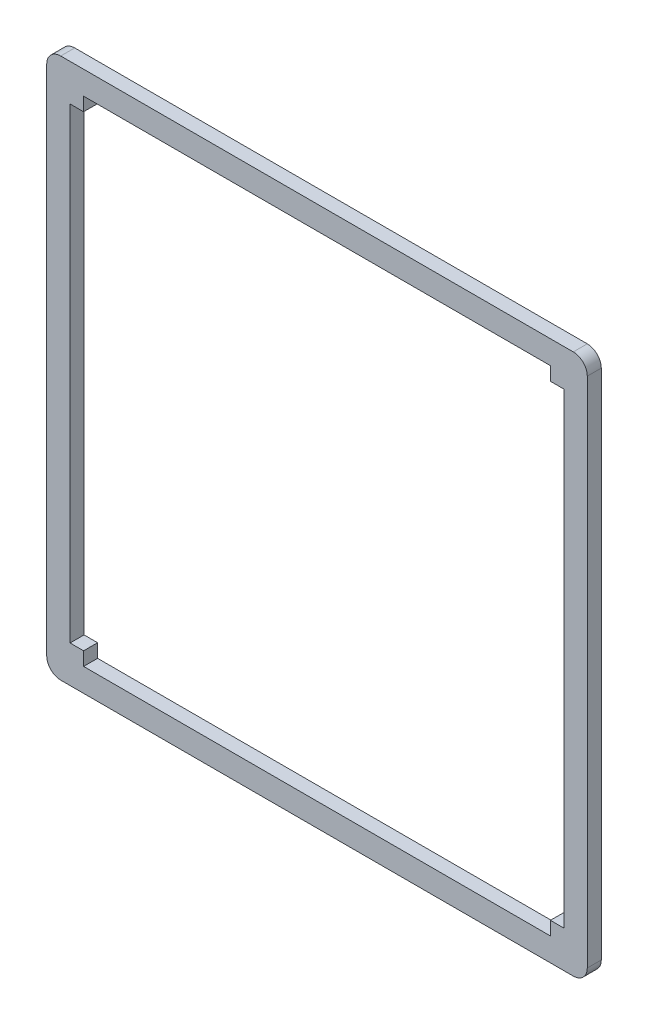
from build123d import *

# Parameters (mm, degrees)
EXTRUDE_1_DEPTH = 3


with BuildPart() as part:
    # 草图1 → 凸台-拉伸1 (new body)
    with BuildSketch(Plane.XY):
        with BuildLine():
            Line((-4.9, 107.9), (104.9, 107.9))
            ThreePointArc((104.9, 107.9), (107.021320344, 107.021320344), (107.9, 104.9))
            Line((107.9, 104.9), (107.9, -4.9))
            ThreePointArc((107.9, -4.9), (107.021320344, -7.021320344), (104.9, -7.9))
            Line((104.9, -7.9), (-4.9, -7.9))
            ThreePointArc((-4.9, -7.9), (-7.021320344, -7.021320344), (-7.9, -4.9))
            Line((-7.9, -4.9), (-7.9, 104.9))
            ThreePointArc((-7.9, 104.9), (-7.021320344, 107.021320344), (-4.9, 107.9))
        make_face()
        Polygon((100, -2.9), (0, -2.9), (0, 0), (-2.9, 0), (-2.9, 100), (0, 100), (0, 102.9), (100, 102.9), (100, 100), (102.9, 100), (102.9, 0), (100, 0), align=None, mode=Mode.SUBTRACT)
    extrude(amount=EXTRUDE_1_DEPTH)


solid = part.part
